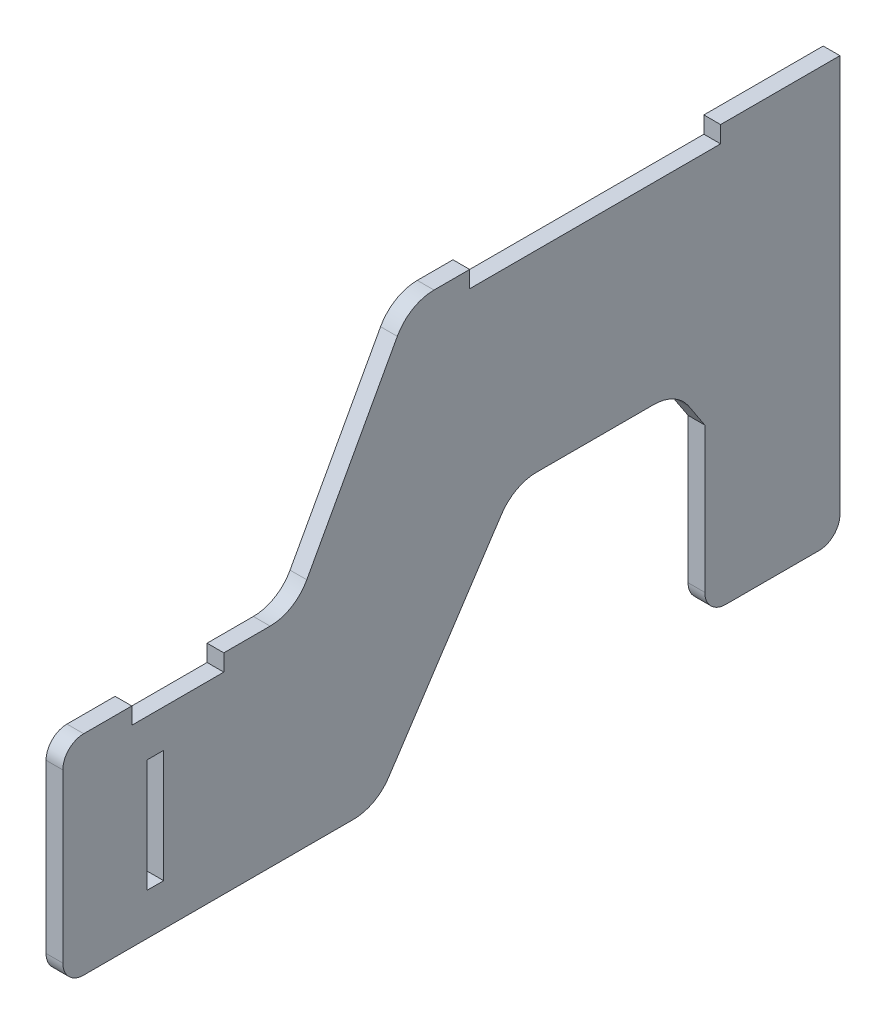
from build123d import *

# Parameters (mm, degrees)
SKETCH2_W           = 4
SKETCH2_H           = 27
BOSS_EXTRUDE1_DEPTH = 4
CUT_EXTRUDE1_DEPTH  = 10
BOSS_EXTRUDE2_DEPTH = 4


with BuildPart() as part:
    # Sketch2 → Boss-Extrude1 (new body)
    with BuildSketch(Plane(origin=(0, 0, 0), x_dir=(0, 0, -1), z_dir=(1, 0, 0))):
        with BuildLine():
            Line((53.344601804, -85.498776043), (74.987188297, -45.905868036))
            ThreePointArc((74.987188297, -45.905868036), (78.661054663, -42.101027368), (83.761812448, -40.70232204))
            Line((83.761812448, -40.70232204), (92.296503371, -40.70232204))
            Line((92.296503371, -40.70232204), (92.296503371, -44.70232204))
            Line((92.296503371, -44.70232204), (152.296503371, -44.70232204))
            Line((152.296503371, -44.70232204), (152.296503371, -40.70232204))
            Line((152.296503371, -40.70232204), (160.831194294, -40.70232204))
            ThreePointArc((160.831194294, -40.70232204), (165.931952079, -42.101027368), (169.605818445, -45.905868036))
            Line((169.605818445, -45.905868036), (191.248404938, -85.498776043))
            ThreePointArc((191.248404938, -85.498776043), (194.922271304, -89.303616711), (200.023029089, -90.70232204))
            Line((200.023029089, -90.70232204), (206.057918615, -90.70232204))
            Line((206.057918615, -90.70232204), (211.09280814, -90.70232204))
            Line((211.09280814, -90.70232204), (211.09280814, -94.70232204))
            Line((211.09280814, -94.70232204), (233.09280814, -94.70232204))
            Line((233.09280814, -94.70232204), (233.09280814, -90.70232204))
            Line((233.09280814, -90.70232204), (244.938223676, -90.70232204))
            ThreePointArc((244.938223676, -90.70232204), (248.5155042, -92.209033609), (249.936812742, -95.821096417))
            Line((249.936812742, -95.821096417), (248.986349517, -135.821096417))
            ThreePointArc((248.986349517, -135.821096417), (247.481048882, -139.279602563), (243.987760452, -140.70232204))
            Line((243.987760452, -140.70232204), (180.035244387, -140.70232204))
            ThreePointArc((180.035244387, -140.70232204), (175.292734587, -139.506218949), (171.684730912, -136.204042199))
            Line((171.684730912, -136.204042199), (144.669691073, -95.20060188))
            ThreePointArc((144.669691073, -95.20060188), (141.061687399, -91.89842513), (136.319177599, -90.70232204))
            Line((136.319177599, -90.70232204), (108.273829143, -90.70232204))
            ThreePointArc((108.273829143, -90.70232204), (103.531319343, -91.89842513), (99.923315669, -95.20060188))
            Line((99.923315669, -95.20060188), (72.90827583, -136.204042199))
            ThreePointArc((72.90827583, -136.204042199), (69.300272155, -139.506218949), (64.557762355, -140.70232204))
            Line((64.557762355, -140.70232204), (0, -140.70232204))
            ThreePointArc((0, -140.70232204), (-3.535533906, -139.237855945), (-5, -135.70232204))
            Line((-5, -135.70232204), (-5, -95.70232204))
            ThreePointArc((-5, -95.70232204), (-3.535533906, -92.166788134), (0, -90.70232204))
            Line((0, -90.70232204), (11.500198602, -90.70232204))
            Line((11.500198602, -90.70232204), (11.500198602, -94.70232204))
            Line((11.500198602, -94.70232204), (33.500198602, -94.70232204))
            Line((33.500198602, -94.70232204), (33.500198602, -90.70232204))
            Line((33.500198602, -90.70232204), (38.535088127, -90.70232204))
            Line((38.535088127, -90.70232204), (44.569977653, -90.70232204))
            ThreePointArc((44.569977653, -90.70232204), (49.670735438, -89.303616711), (53.344601804, -85.498776043))
        make_face()
        with Locations((227.463006742, -117.20232204)):
            Rectangle(SKETCH2_W, SKETCH2_H, mode=Mode.SUBTRACT)
        with Locations((17.13, -117.20232204)):
            Rectangle(SKETCH2_W, SKETCH2_H, mode=Mode.SUBTRACT)
    extrude(amount=BOSS_EXTRUDE1_DEPTH)

    # Sketch3 → Cut-Extrude1 (cut)
    with BuildSketch(Plane(origin=(0, 0, 0), x_dir=(0, 0, -1), z_dir=(1, 0, 0))):
        Polygon((160.831194294, -40.70232204), (160.831194294, -144.460869934), (257.875348239, -144.460869934), (257.875348239, -25.544082069), (160.831194294, -34.903829247), align=None)
    extrude(amount=CUT_EXTRUDE1_DEPTH, mode=Mode.SUBTRACT)

    # Sketch4 → Boss-Extrude2 (add)
    with BuildSketch(Plane(origin=(0, 0, 0), x_dir=(0, 0, -1), z_dir=(1, 0, 0))):
        with BuildLine():
            Line((160.831194294, -40.70232204), (180.831194294, -40.70232204))
            Line((180.831194294, -40.70232204), (180.831194294, -135.70232204))
            ThreePointArc((180.831194294, -135.70232204), (179.3667282, -139.237855945), (175.831194294, -140.70232204))
            Line((175.831194294, -140.70232204), (153.525004458, -140.70232204))
            ThreePointArc((153.525004458, -140.70232204), (149.989470552, -139.237855945), (148.525004458, -135.70232204))
            Line((148.525004458, -135.70232204), (148.525004458, -101.052198369))
            Line((148.525004458, -101.052198369), (160.831194294, -40.70232204))
        make_face()
    extrude(amount=BOSS_EXTRUDE2_DEPTH)


solid = part.part
